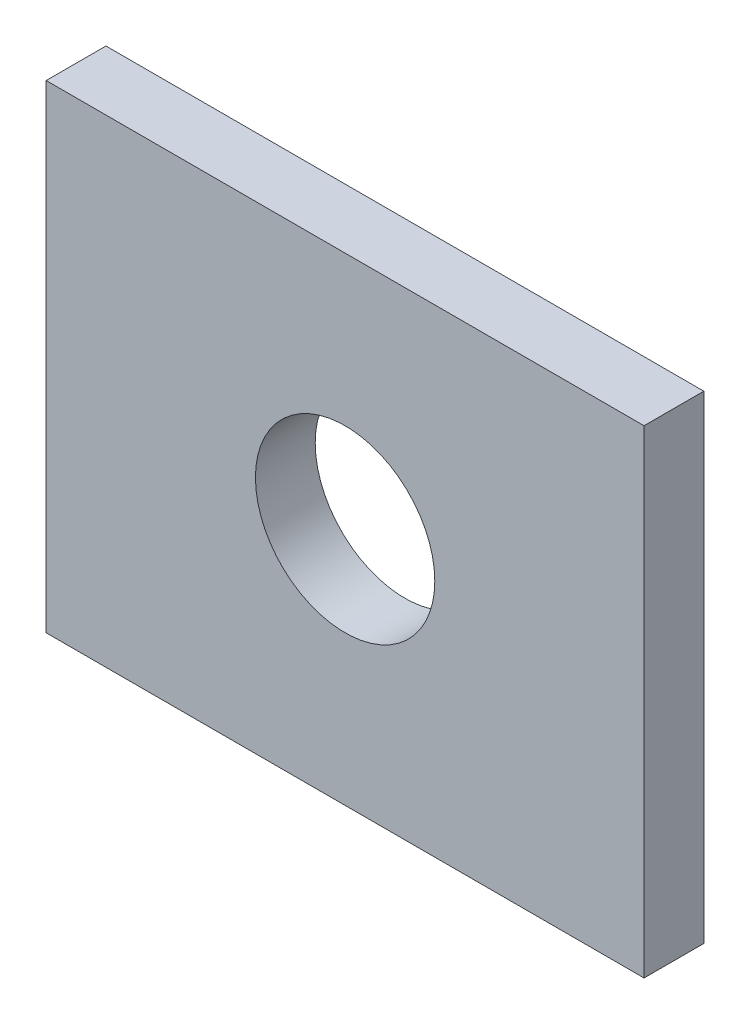
from build123d import *

# Parameters (mm, degrees)
SKETCH1_W           = 10
SKETCH1_H           = 8
SKETCH1_R           = 1.5
BOSS_EXTRUDE1_DEPTH = 0.5


with BuildPart() as part:
    # Sketch1 → Boss-Extrude1 (new body, symmetric)
    with BuildSketch(Plane.XY):
        Rectangle(SKETCH1_W, SKETCH1_H)
        Circle(SKETCH1_R, mode=Mode.SUBTRACT)
    extrude(amount=BOSS_EXTRUDE1_DEPTH, both=True)


solid = part.part
